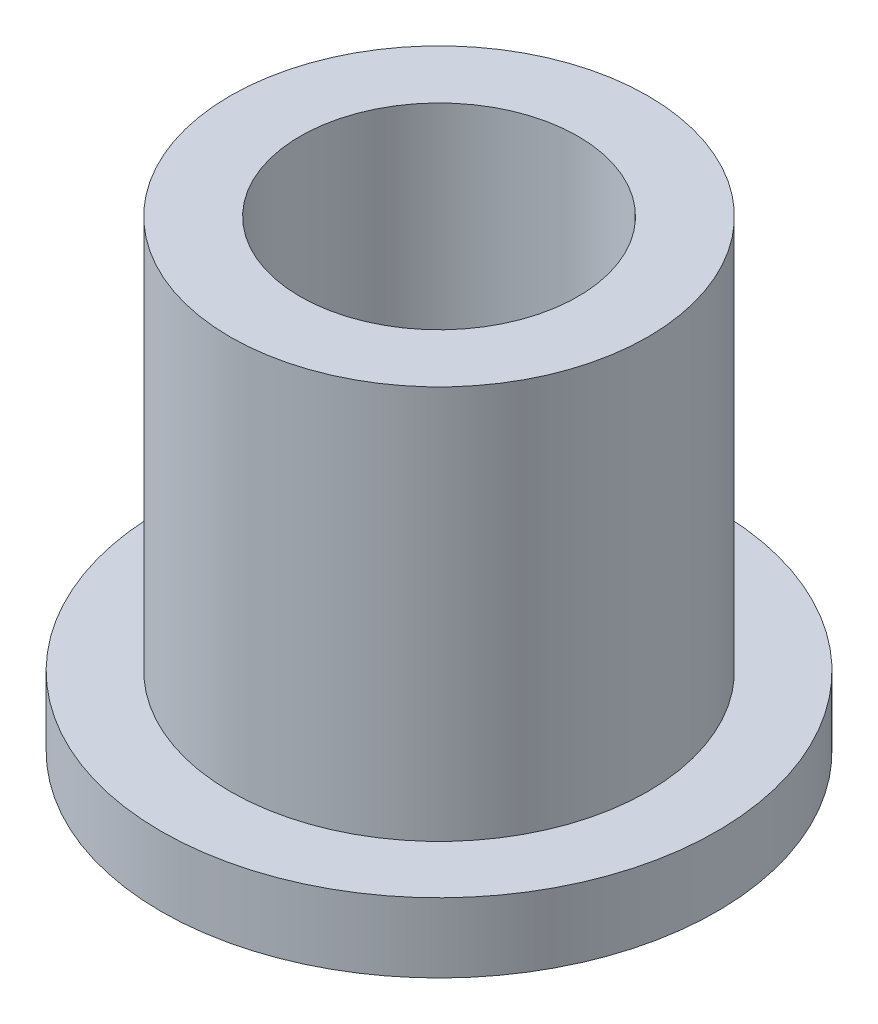
from build123d import *

# Parameters (mm, degrees)
SKETCH2_R           = 4.51
SKETCH2_R_2         = 3
BOSS_EXTRUDE1_DEPTH = 10
SKETCH3_R           = 6
SKETCH3_R_2         = 4.51
BOSS_EXTRUDE2_DEPTH = 1.5


with BuildPart() as part:
    # Sketch2 → Boss-Extrude1 (new body)
    with BuildSketch(Plane(origin=(0, 0, 0), x_dir=(1, 0, 0), z_dir=(0, 1, 0))):
        Circle(SKETCH2_R)
        Circle(SKETCH2_R_2, mode=Mode.SUBTRACT)
    extrude(amount=BOSS_EXTRUDE1_DEPTH)

    # Sketch3 → Boss-Extrude2 (add)
    with BuildSketch(Plane(origin=(0, 0, 0), x_dir=(1, 0, 0), z_dir=(0, 1, 0))):
        Circle(SKETCH3_R)
        Circle(SKETCH3_R_2, mode=Mode.SUBTRACT)
    extrude(amount=BOSS_EXTRUDE2_DEPTH)


solid = part.part
